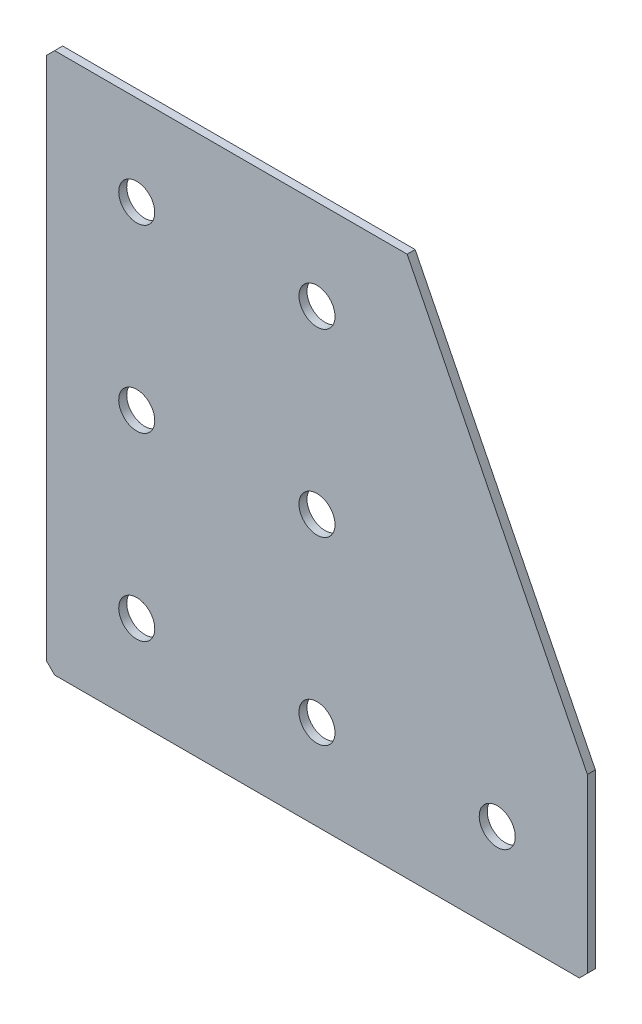
from build123d import *

# Parameters (mm, degrees)
EXTRUDE_1_DEPTH   = 2
HOLE_WIZARD_M81_D = 9
CHAMFER_1_SIZE    = 2


with BuildPart() as part:
    # Эскиз1 → Бобышка-Вытянуть1 (new body)
    with BuildSketch(Plane(origin=(0, 0, 0), x_dir=(1, 0, 0), z_dir=(0, 0, -1))):
        Polygon((0, 0), (0, 135), (135, 135), (135, 90), (90, 0), align=None)
    extrude(amount=EXTRUDE_1_DEPTH)

    # Отверстие с зазором M81 (through all)
    with Locations(Plane(origin=(0, 0, -2), x_dir=(1, 0, 0), z_dir=(0, 0, -1))):
        with Locations((67.5, 112.5), (22.5, 112.5), (22.5, 67.5), (22.5, 22.5), (112.5, 112.5), (67.5, 67.5), (67.5, 22.5)):
            Hole(HOLE_WIZARD_M81_D / 2)

    # Фаска1
    chamfer_1_edges = [part.edges().sort_by_distance(p)[0] for p in [
        (0, 0, -1),
        (0, -135, -1),
        (135, -135, -1),
    ]]
    chamfer(chamfer_1_edges, length=CHAMFER_1_SIZE)


solid = part.part
